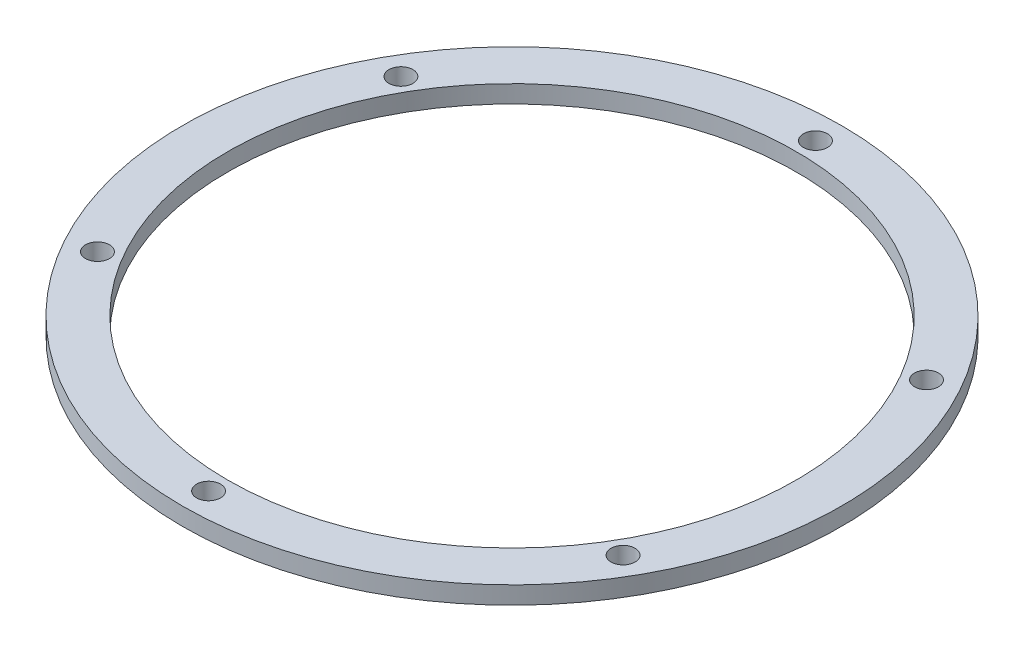
from build123d import *

# Parameters (mm, degrees)
SKETCH1_R           = 59.309
SKETCH1_R_2         = 51.181
BOSS_EXTRUDE1_DEPTH = 3.175
SKETCH2_R           = 2.159
CUT_EXTRUDE1_DEPTH  = 3.175
CIRPATTERN1_COUNT   = 6


with BuildPart() as part:
    # Sketch1 → Boss-Extrude1 (new body)
    with BuildSketch(Plane(origin=(0, 0, 0), x_dir=(1, 0, 0), z_dir=(0, 1, 0))):
        Circle(SKETCH1_R)
        Circle(SKETCH1_R_2, mode=Mode.SUBTRACT)
    extrude(amount=BOSS_EXTRUDE1_DEPTH)

    # Sketch2 → Cut-Extrude1 (cut)
    with BuildSketch(Plane(origin=(0, 3.175, 0), x_dir=(1, 0, 0), z_dir=(0, 1, 0))):
        with Locations((0, 54.61)):
            Circle(SKETCH2_R)
    cut_extrude1 = extrude(amount=-CUT_EXTRUDE1_DEPTH, mode=Mode.SUBTRACT)

    # CirPattern1: Cut-Extrude1 ×6 about axis
    cirpattern1_axis = Axis((0, 0, 0), (0, 1, 0))
    for i in range(1, CIRPATTERN1_COUNT):
        add(cut_extrude1.rotate(cirpattern1_axis, i * 360 / CIRPATTERN1_COUNT), mode=Mode.SUBTRACT)


solid = part.part
